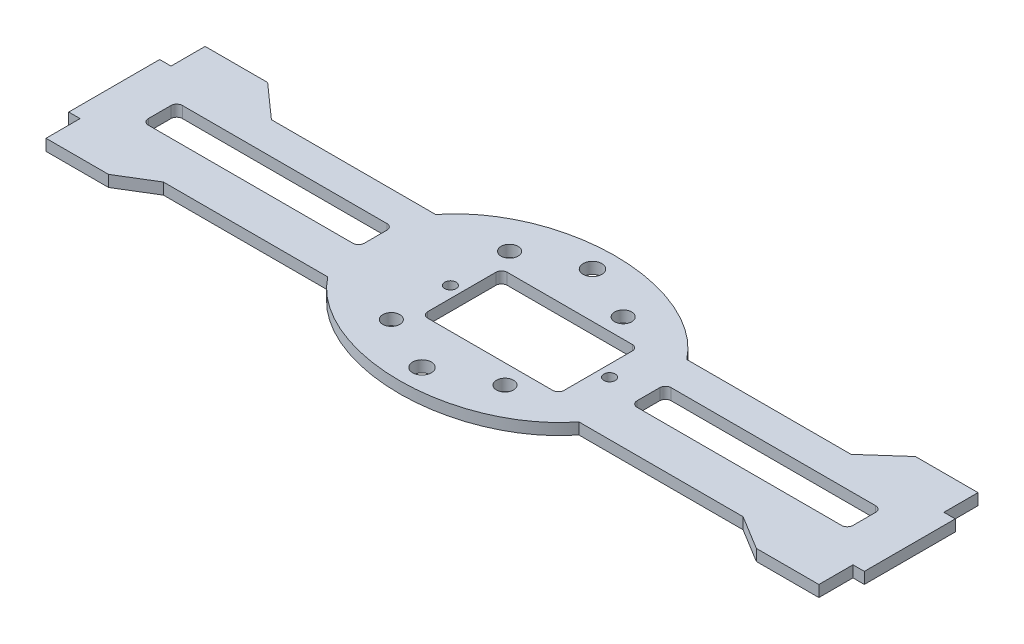
from build123d import *

# Parameters (mm, degrees)
RESSALTO_EXTRUS_O1_DEPTH = 2
ESBO_O2_R                = 1.65
ESBO_O2_R_2              = 1.5
ESBO_O2_R_3              = 1
CORTE_EXTRUS_O1_DEPTH    = 3.0000001


with BuildPart() as part:
    # Esboço1 → Ressalto-extrusão1 (new body)
    with BuildSketch(Plane(origin=(0, 0, 0), x_dir=(1, 0, 0), z_dir=(0, 1, 0))):
        with BuildLine():
            Line((-57, 14.836150135), (-51, 9.5))
            Line((-51, 9.5), (-22.083647797, 9.5))
            add(Edge.make_bspline(
                [(22.083647797, 9.5), (0, 38), (-22.083647797, 9.5)],
                knots=[0.523598776, 0.523598776, 0.523598776, 2.617993878, 2.617993878, 2.617993878], degree=2, weights=[1, 0.5, 1]))
            Line((22.083647797, 9.5), (51, 9.5))
            Line((51, 9.5), (57, 14.836150135))
            Line((57, 14.836150135), (68, 14.836150135))
            Line((68, 14.836150135), (68, 8.836150135))
            Line((68, 8.836150135), (70, 8.836150135))
            Line((70, 8.836150135), (70, -7.163849865))
            Line((70, -7.163849865), (68, -7.163849865))
            Line((68, -7.163849865), (68, -13.163849865))
            Line((68, -13.163849865), (57, -13.163849865))
            Line((57, -13.163849865), (51, -9.5))
            Line((51, -9.5), (22.083647797, -9.5))
            add(Edge.make_bspline(
                [(-22.083647797, -9.5), (0, -38), (22.083647797, -9.5)],
                knots=[3.665191429, 3.665191429, 3.665191429, 5.759586532, 5.759586532, 5.759586532], degree=2, weights=[1, 0.5, 1]))
            Line((-22.083647797, -9.5), (-51, -9.5))
            Line((-51, -9.5), (-57, -13.163849865))
            Line((-57, -13.163849865), (-68, -13.163849865))
            Line((-68, -13.163849865), (-68, -7.163849865))
            Line((-68, -7.163849865), (-70, -7.163849865))
            Line((-70, -7.163849865), (-70, 8.836150135))
            Line((-70, 8.836150135), (-68, 8.836150135))
            Line((-68, 8.836150135), (-68, 14.836150135))
            Line((-68, 14.836150135), (-57, 14.836150135))
        make_face()
    extrude(amount=RESSALTO_EXTRUS_O1_DEPTH)

    # Esboço2 → Corte-extrusão1 (cut, through all)
    with BuildSketch(Plane(origin=(0, 2, 0), x_dir=(1, 0, 0), z_dir=(0, 1, 0))):
        with Locations((0, 15)):
            Circle(ESBO_O2_R)
        with Locations((10, 10.4)):
            Circle(ESBO_O2_R_2)
        with Locations((-10, 10.4)):
            Circle(ESBO_O2_R_2)
        with Locations((0, -15)):
            Circle(ESBO_O2_R)
        with Locations((10, -10.4)):
            Circle(ESBO_O2_R_2)
        with Locations((-10, -10.4)):
            Circle(ESBO_O2_R_2)
        with Locations((-10, 0)):
            Circle(ESBO_O2_R_3)
        with Locations((18, 0)):
            Circle(ESBO_O2_R_3)
        with BuildLine():
            Line((25, 3.836150135), (61, 3.836150135))
            ThreePointArc((61, 3.836150135), (61.707106781, 3.543256916), (62, 2.836150135))
            Line((62, 2.836150135), (62, -1.163849865))
            ThreePointArc((62, -1.163849865), (61.707106781, -1.870956646), (61, -2.163849865))
            Line((61, -2.163849865), (25, -2.163849865))
            ThreePointArc((25, -2.163849865), (24.292893219, -1.870956646), (24, -1.163849865))
            Line((24, -1.163849865), (24, 2.836150135))
            ThreePointArc((24, 2.836150135), (24.292893219, 3.543256916), (25, 3.836150135))
        make_face()
        with BuildLine():
            Line((-61, 3.836150135), (-25, 3.836150135))
            ThreePointArc((-25, 3.836150135), (-24.292893219, 3.543256916), (-24, 2.836150135))
            Line((-24, 2.836150135), (-24, -1.163849865))
            ThreePointArc((-24, -1.163849865), (-24.292893219, -1.870956646), (-25, -2.163849865))
            Line((-25, -2.163849865), (-61, -2.163849865))
            ThreePointArc((-61, -2.163849865), (-61.707106781, -1.870956646), (-62, -1.163849865))
            Line((-62, -1.163849865), (-62, 2.836150135))
            ThreePointArc((-62, 2.836150135), (-61.707106781, 3.543256916), (-61, 3.836150135))
        make_face()
        with BuildLine():
            Line((-7, 7), (15, 7))
            ThreePointArc((15, 7), (15.707106781, 6.707106781), (16, 6))
            Line((16, 6), (16, -6))
            ThreePointArc((16, -6), (15.707106781, -6.707106781), (15, -7))
            Line((15, -7), (-7, -7))
            ThreePointArc((-7, -7), (-7.707106781, -6.707106781), (-8, -6))
            Line((-8, -6), (-8, 6))
            ThreePointArc((-8, 6), (-7.707106781, 6.707106781), (-7, 7))
        make_face()
    extrude(amount=-CORTE_EXTRUS_O1_DEPTH, mode=Mode.SUBTRACT)


solid = part.part
